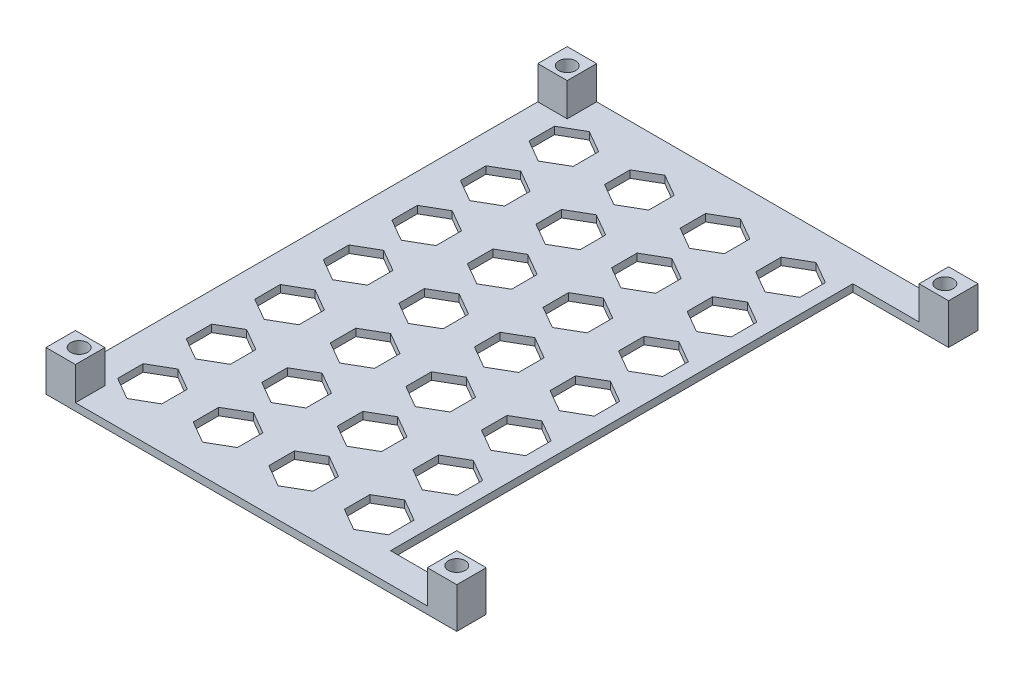
from build123d import *

# Parameters (mm, degrees)
BOSS_EXTRUDE1_DEPTH  = 1
CUT_EXTRUDE1_DEPTH   = 1
LPATTERN1_COUNT      = 4
LPATTERN1_PITCH      = 10.266666667
LPATTERN1_COUNT_DIR2 = 7
LPATTERN1_PITCH_DIR2 = 9.311966128
SKETCH3_W            = 4
SKETCH3_H            = 4
BOSS_EXTRUDE2_DEPTH  = 4.5
SKETCH4_R            = 1.15
CUT_EXTRUDE2_DEPTH   = 5.5


with BuildPart() as part:
    # Sketch1 → Boss-Extrude1 (new body)
    with BuildSketch(Plane(origin=(0, 0, 0), x_dir=(1, 0, 0), z_dir=(0, 1, 0))):
        Polygon((0, 0), (55.8, 0), (55.8, 4), (42.8, 4), (42.8, 66.8), (55.8, 66.8), (55.8, 70.8), (0, 70.8), align=None)
    extrude(amount=BOSS_EXTRUDE1_DEPTH)

    # Sketch2 → Cut-Extrude1 (cut)
    with BuildSketch(Plane(origin=(0, 1, 0), x_dir=(1, 0, 0), z_dir=(0, 1, 0))):
        Polygon((7, 66.8), (4, 65.067949192), (4, 61.603847577), (7, 59.87179677), (10, 61.603847577), (10, 65.067949192), align=None)
    cut_extrude1 = extrude(amount=-CUT_EXTRUDE1_DEPTH, mode=Mode.SUBTRACT)

    # LPattern1: Cut-Extrude1 4 × 7
    with Locations(*[(i * LPATTERN1_PITCH, 0, j * LPATTERN1_PITCH_DIR2) for i in range(LPATTERN1_COUNT) for j in range(LPATTERN1_COUNT_DIR2) if (i, j) != (0, 0)]):
        add(cut_extrude1, mode=Mode.SUBTRACT)

    # Sketch3 → Boss-Extrude2 (add)
    with BuildSketch(Plane(origin=(0, 1, 0), x_dir=(1, 0, 0), z_dir=(0, 1, 0))):
        with Locations((2, 68.8)):
            Rectangle(SKETCH3_W, SKETCH3_H)
        with Locations((53.8, 68.8)):
            Rectangle(SKETCH3_W, SKETCH3_H)
        with Locations((53.8, 2)):
            Rectangle(SKETCH3_W, SKETCH3_H)
        with Locations((2, 2)):
            Rectangle(SKETCH3_W, SKETCH3_H)
    extrude(amount=BOSS_EXTRUDE2_DEPTH)

    # Sketch4 → Cut-Extrude2 (cut)
    with BuildSketch(Plane(origin=(0, 5.5, 0), x_dir=(1, 0, 0), z_dir=(0, 1, 0))):
        with Locations((2.25, 68.55)):
            Circle(SKETCH4_R)
        with Locations((53.55, 68.55)):
            Circle(SKETCH4_R)
    cut_extrude2 = extrude(amount=-CUT_EXTRUDE2_DEPTH, mode=Mode.SUBTRACT)

    # Mirror1: Cut-Extrude2 across plane
    add(cut_extrude2.mirror(Plane(origin=(0, 0, -35.4), x_dir=(1, 0, 0), z_dir=(0, 0, -1))), mode=Mode.SUBTRACT)


solid = part.part
